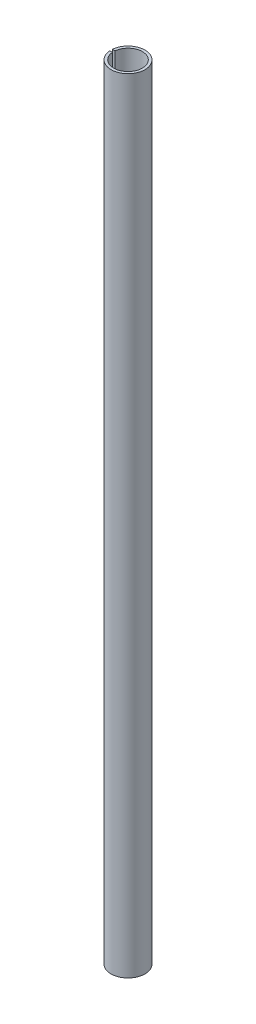
from build123d import *

# Parameters (mm, degrees)
SKETCH_1_R          = 13
SKETCH_1_R_2        = 11
EXTRUDE_1_DEPTH     = 600
SKETCH_2_W          = 2
SKETCH_2_H          = 30
CUT_EXTRUDE_1_DEPTH = 14


with BuildPart() as part:
    # 草图1 → 凸台-拉伸1 (new body)
    with BuildSketch(Plane(origin=(0, 0, 0), x_dir=(1, 0, 0), z_dir=(0, 1, 0))):
        Circle(SKETCH_1_R)
        Circle(SKETCH_1_R_2, mode=Mode.SUBTRACT)
    extrude(amount=EXTRUDE_1_DEPTH)

    # 草图2 → 切除-拉伸1 (cut, through all)
    with BuildSketch(Plane(origin=(0, 0, 0), x_dir=(0, 0, -1), z_dir=(1, 0, 0))):
        with Locations((0, 585)):
            Rectangle(SKETCH_2_W, SKETCH_2_H)
        with Locations((0, 15)):
            Rectangle(SKETCH_2_W, SKETCH_2_H)
    extrude(amount=-CUT_EXTRUDE_1_DEPTH, mode=Mode.SUBTRACT)


solid = part.part
